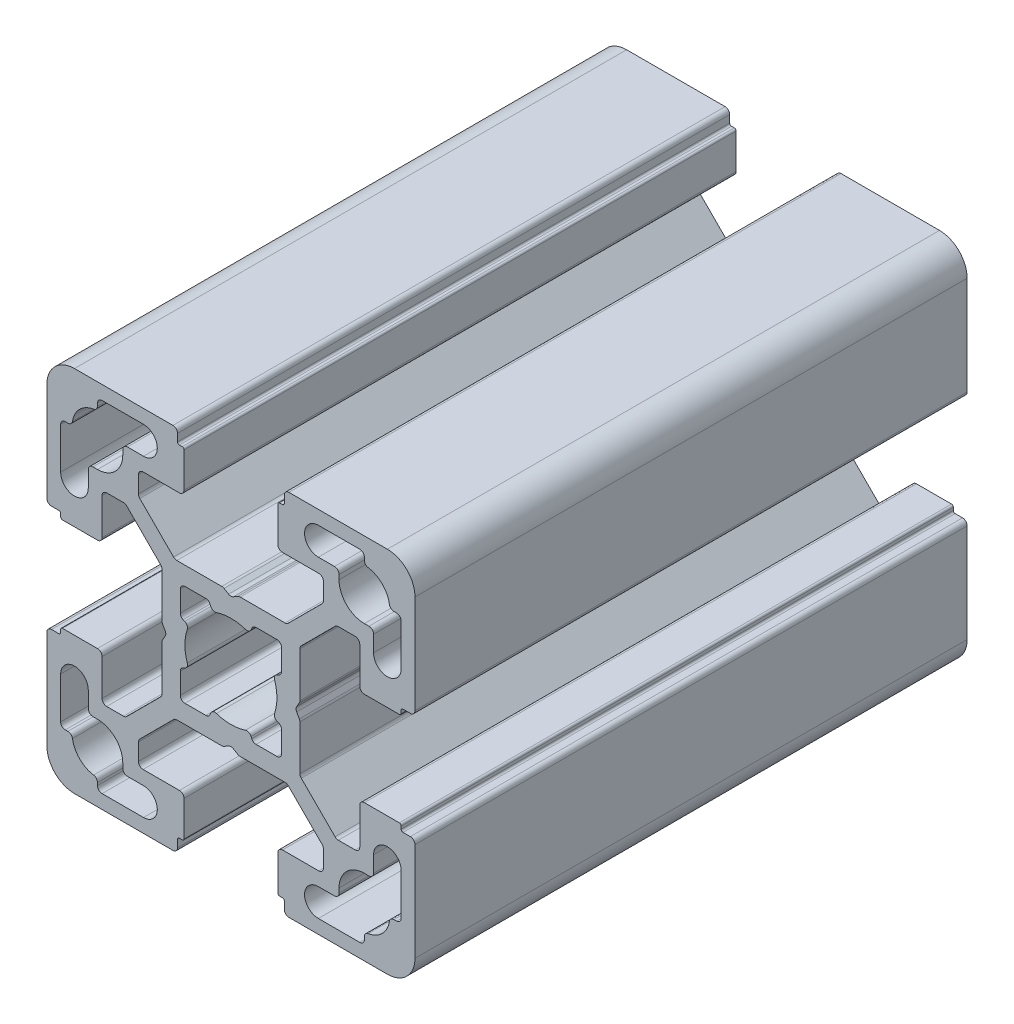
from build123d import *

# Parameters (mm, degrees)
EXTRUDE_1_DEPTH = 60


with BuildPart() as part:
    # Эскиз1 → Бобышка-Вытянуть1 (new body)
    with BuildSketch(Plane.XY):
        with BuildLine():
            Line((-18.5, -5.6), (-18.5, -5.3))
            ThreePointArc((-18.5, -5.3), (-18.441421356, -5.158578644), (-18.3, -5.1))
            Line((-18.3, -5.1), (-14.5, -5.1))
            ThreePointArc((-14.5, -5.1), (-14.146446609, -5.246446609), (-14, -5.6))
            Line((-14, -5.6), (-14, -9.55))
            ThreePointArc((-14, -9.55), (-13.853553391, -9.903553391), (-13.5, -10.05))
            Line((-13.5, -10.05), (-11.671320344, -10.05))
            ThreePointArc((-11.671320344, -10.05), (-11.479978627, -10.011939766), (-11.317766953, -9.903553391))
            Line((-11.317766953, -9.903553391), (-7.646446609, -6.232233047))
            ThreePointArc((-7.646446609, -6.232233047), (-7.538060234, -6.070021373), (-7.5, -5.878679656))
            Line((-7.5, -5.878679656), (-7.5, -1))
            ThreePointArc((-7.5, -1), (-7.482962913, -0.870590477), (-7.433012702, -0.75))
            Line((-7.433012702, -0.75), (-7.144337567, -0.25))
            ThreePointArc((-7.144337567, -0.25), (-7.077350269, 0), (-7.144337567, 0.25))
            Line((-7.144337567, 0.25), (-7.433012702, 0.75))
            ThreePointArc((-7.433012702, 0.75), (-7.482962913, 0.870590477), (-7.5, 1))
            Line((-7.5, 1), (-7.5, 5.878679656))
            ThreePointArc((-7.5, 5.878679656), (-7.538060234, 6.070021373), (-7.646446609, 6.232233047))
            Line((-7.646446609, 6.232233047), (-11.317766953, 9.903553391))
            ThreePointArc((-11.317766953, 9.903553391), (-11.479978627, 10.011939766), (-11.671320344, 10.05))
            Line((-11.671320344, 10.05), (-13.5, 10.05))
            ThreePointArc((-13.5, 10.05), (-13.853553391, 9.903553391), (-14, 9.55))
            Line((-14, 9.55), (-14, 5.6))
            ThreePointArc((-14, 5.6), (-14.146446609, 5.246446609), (-14.5, 5.1))
            Line((-14.5, 5.1), (-18.3, 5.1))
            ThreePointArc((-18.3, 5.1), (-18.441421356, 5.158578644), (-18.5, 5.3))
            Line((-18.5, 5.3), (-18.5, 5.6))
            ThreePointArc((-18.5, 5.6), (-18.558578644, 5.741421356), (-18.7, 5.8))
            Line((-18.7, 5.8), (-19.5, 5.8))
            ThreePointArc((-19.5, 5.8), (-19.853553391, 5.946446609), (-20, 6.3))
            Line((-20, 6.3), (-20, 17))
            ThreePointArc((-20, 17), (-19.121320344, 19.121320344), (-17, 20))
            Line((-17, 20), (-6.3, 20))
            ThreePointArc((-6.3, 20), (-5.946446609, 19.853553391), (-5.8, 19.5))
            Line((-5.8, 19.5), (-5.8, 18.7))
            ThreePointArc((-5.8, 18.7), (-5.741421356, 18.558578644), (-5.6, 18.5))
            Line((-5.6, 18.5), (-5.3, 18.5))
            ThreePointArc((-5.3, 18.5), (-5.158578644, 18.441421356), (-5.1, 18.3))
            Line((-5.1, 18.3), (-5.1, 14.5))
            ThreePointArc((-5.1, 14.5), (-5.246446609, 14.146446609), (-5.6, 14))
            Line((-5.6, 14), (-9.55, 14))
            ThreePointArc((-9.55, 14), (-9.903553391, 13.853553391), (-10.05, 13.5))
            Line((-10.05, 13.5), (-10.05, 11.671320344))
            ThreePointArc((-10.05, 11.671320344), (-10.011939766, 11.479978627), (-9.903553391, 11.317766953))
            Line((-9.903553391, 11.317766953), (-6.232233047, 7.646446609))
            ThreePointArc((-6.232233047, 7.646446609), (-6.070021373, 7.538060234), (-5.878679656, 7.5))
            Line((-5.878679656, 7.5), (-1, 7.5))
            ThreePointArc((-1, 7.5), (-0.870590477, 7.482962913), (-0.75, 7.433012702))
            Line((-0.75, 7.433012702), (-0.25, 7.144337567))
            ThreePointArc((-0.25, 7.144337567), (0, 7.077350269), (0.25, 7.144337567))
            Line((0.25, 7.144337567), (0.75, 7.433012702))
            ThreePointArc((0.75, 7.433012702), (0.870590477, 7.482962913), (1, 7.5))
            Line((1, 7.5), (5.878679656, 7.5))
            ThreePointArc((5.878679656, 7.5), (6.070021373, 7.538060234), (6.232233047, 7.646446609))
            Line((6.232233047, 7.646446609), (9.903553391, 11.317766953))
            ThreePointArc((9.903553391, 11.317766953), (10.011939766, 11.479978627), (10.05, 11.671320344))
            Line((10.05, 11.671320344), (10.05, 13.5))
            ThreePointArc((10.05, 13.5), (9.903553391, 13.853553391), (9.55, 14))
            Line((9.55, 14), (5.6, 14))
            ThreePointArc((5.6, 14), (5.246446609, 14.146446609), (5.1, 14.5))
            Line((5.1, 14.5), (5.1, 18.3))
            ThreePointArc((5.1, 18.3), (5.158578644, 18.441421356), (5.3, 18.5))
            Line((5.3, 18.5), (5.6, 18.5))
            ThreePointArc((5.6, 18.5), (5.741421356, 18.558578644), (5.8, 18.7))
            Line((5.8, 18.7), (5.8, 19.5))
            ThreePointArc((5.8, 19.5), (5.946446609, 19.853553391), (6.3, 20))
            Line((6.3, 20), (17, 20))
            ThreePointArc((17, 20), (19.121320344, 19.121320344), (20, 17))
            Line((20, 17), (20, 6.3))
            ThreePointArc((20, 6.3), (19.853553391, 5.946446609), (19.5, 5.8))
            Line((19.5, 5.8), (18.7, 5.8))
            ThreePointArc((18.7, 5.8), (18.558578644, 5.741421356), (18.5, 5.6))
            Line((18.5, 5.6), (18.5, 5.3))
            ThreePointArc((18.5, 5.3), (18.441421356, 5.158578644), (18.3, 5.1))
            Line((18.3, 5.1), (14.5, 5.1))
            ThreePointArc((14.5, 5.1), (14.146446609, 5.246446609), (14, 5.6))
            Line((14, 5.6), (14, 9.55))
            ThreePointArc((14, 9.55), (13.853553391, 9.903553391), (13.5, 10.05))
            Line((13.5, 10.05), (11.671320344, 10.05))
            ThreePointArc((11.671320344, 10.05), (11.479978627, 10.011939766), (11.317766953, 9.903553391))
            Line((11.317766953, 9.903553391), (7.646446609, 6.232233047))
            ThreePointArc((7.646446609, 6.232233047), (7.538060234, 6.070021373), (7.5, 5.878679656))
            Line((7.5, 5.878679656), (7.5, 1))
            ThreePointArc((7.5, 1), (7.482962913, 0.870590477), (7.433012702, 0.75))
            Line((7.433012702, 0.75), (7.144337567, 0.25))
            ThreePointArc((7.144337567, 0.25), (7.077350269, 0), (7.144337567, -0.25))
            Line((7.144337567, -0.25), (7.433012702, -0.75))
            ThreePointArc((7.433012702, -0.75), (7.482962913, -0.870590477), (7.5, -1))
            Line((7.5, -1), (7.5, -5.878679656))
            ThreePointArc((7.5, -5.878679656), (7.538060234, -6.070021373), (7.646446609, -6.232233047))
            Line((7.646446609, -6.232233047), (11.317766953, -9.903553391))
            ThreePointArc((11.317766953, -9.903553391), (11.479978627, -10.011939766), (11.671320344, -10.05))
            Line((11.671320344, -10.05), (13.5, -10.05))
            ThreePointArc((13.5, -10.05), (13.853553391, -9.903553391), (14, -9.55))
            Line((14, -9.55), (14, -5.6))
            ThreePointArc((14, -5.6), (14.146446609, -5.246446609), (14.5, -5.1))
            Line((14.5, -5.1), (18.3, -5.1))
            ThreePointArc((18.3, -5.1), (18.441421356, -5.158578644), (18.5, -5.3))
            Line((18.5, -5.3), (18.5, -5.6))
            ThreePointArc((18.5, -5.6), (18.558578644, -5.741421356), (18.7, -5.8))
            Line((18.7, -5.8), (19.5, -5.8))
            ThreePointArc((19.5, -5.8), (19.853553391, -5.946446609), (20, -6.3))
            Line((20, -6.3), (20, -17))
            ThreePointArc((20, -17), (19.121320344, -19.121320344), (17, -20))
            Line((17, -20), (6.3, -20))
            ThreePointArc((6.3, -20), (5.946446609, -19.853553391), (5.8, -19.5))
            Line((5.8, -19.5), (5.8, -18.7))
            ThreePointArc((5.8, -18.7), (5.741421356, -18.558578644), (5.6, -18.5))
            Line((5.6, -18.5), (5.3, -18.5))
            ThreePointArc((5.3, -18.5), (5.158578644, -18.441421356), (5.1, -18.3))
            Line((5.1, -18.3), (5.1, -14.5))
            ThreePointArc((5.1, -14.5), (5.246446609, -14.146446609), (5.6, -14))
            Line((5.6, -14), (9.55, -14))
            ThreePointArc((9.55, -14), (9.903553391, -13.853553391), (10.05, -13.5))
            Line((10.05, -13.5), (10.05, -11.671320344))
            ThreePointArc((10.05, -11.671320344), (10.011939766, -11.479978627), (9.903553391, -11.317766953))
            Line((9.903553391, -11.317766953), (6.232233047, -7.646446609))
            ThreePointArc((6.232233047, -7.646446609), (6.070021373, -7.538060234), (5.878679656, -7.5))
            Line((5.878679656, -7.5), (1, -7.5))
            ThreePointArc((1, -7.5), (0.870590477, -7.482962913), (0.75, -7.433012702))
            Line((0.75, -7.433012702), (0.25, -7.144337567))
            ThreePointArc((0.25, -7.144337567), (0, -7.077350269), (-0.25, -7.144337567))
            Line((-0.25, -7.144337567), (-0.75, -7.433012702))
            ThreePointArc((-0.75, -7.433012702), (-0.870590477, -7.482962913), (-1, -7.5))
            Line((-1, -7.5), (-5.878679656, -7.5))
            ThreePointArc((-5.878679656, -7.5), (-6.070021373, -7.538060234), (-6.232233047, -7.646446609))
            Line((-6.232233047, -7.646446609), (-9.903553391, -11.317766953))
            ThreePointArc((-9.903553391, -11.317766953), (-10.011939766, -11.479978627), (-10.05, -11.671320344))
            Line((-10.05, -11.671320344), (-10.05, -13.5))
            ThreePointArc((-10.05, -13.5), (-9.903553391, -13.853553391), (-9.55, -14))
            Line((-9.55, -14), (-5.6, -14))
            ThreePointArc((-5.6, -14), (-5.246446609, -14.146446609), (-5.1, -14.5))
            Line((-5.1, -14.5), (-5.1, -18.3))
            ThreePointArc((-5.1, -18.3), (-5.158578644, -18.441421356), (-5.3, -18.5))
            Line((-5.3, -18.5), (-5.6, -18.5))
            ThreePointArc((-5.6, -18.5), (-5.741421356, -18.558578644), (-5.8, -18.7))
            Line((-5.8, -18.7), (-5.8, -19.5))
            ThreePointArc((-5.8, -19.5), (-5.946446609, -19.853553391), (-6.3, -20))
            Line((-6.3, -20), (-17, -20))
            ThreePointArc((-17, -20), (-19.121320344, -19.121320344), (-20, -17))
            Line((-20, -17), (-20, -6.3))
            ThreePointArc((-20, -6.3), (-19.853553391, -5.946446609), (-19.5, -5.8))
            Line((-19.5, -5.8), (-18.7, -5.8))
            ThreePointArc((-18.7, -5.8), (-18.558578644, -5.741421356), (-18.5, -5.6))
        make_face()
        with BuildLine():
            Line((-14.5, 18), (-14.5, 17.711308145))
            ThreePointArc((-14.5, 17.711308145), (-14.620222737, 17.386086327), (-14.923076923, 17.217260738))
            ThreePointArc((-14.923076923, 17.217260738), (-16.444543648, 16.444543648), (-17.217260738, 14.923076923))
            ThreePointArc((-17.217260738, 14.923076923), (-17.386086327, 14.620222737), (-17.711308145, 14.5))
            Line((-17.711308145, 14.5), (-18, 14.5))
            ThreePointArc((-18, 14.5), (-18.353553391, 14.353553391), (-18.5, 14))
            Line((-18.5, 14), (-18.5, 9.5))
            ThreePointArc((-18.5, 9.5), (-17, 8), (-15.5, 9.5))
            Line((-15.5, 9.5), (-15.5, 11.25))
            ThreePointArc((-15.5, 11.25), (-15.353553391, 11.603553391), (-15, 11.75))
            Line((-15, 11.75), (-14.5, 11.75))
            ThreePointArc((-14.5, 11.75), (-12.555456352, 12.555456352), (-11.75, 14.5))
            Line((-11.75, 14.5), (-11.75, 15))
            ThreePointArc((-11.75, 15), (-11.603553391, 15.353553391), (-11.25, 15.5))
            Line((-11.25, 15.5), (-9.5, 15.5))
            ThreePointArc((-9.5, 15.5), (-8, 17), (-9.5, 18.5))
            Line((-9.5, 18.5), (-14, 18.5))
            ThreePointArc((-14, 18.5), (-14.353553391, 18.353553391), (-14.5, 18))
        make_face(mode=Mode.SUBTRACT)
        with BuildLine():
            Line((-5.199374534, 2.269284327), (-5.020474811, 2.191496514))
            ThreePointArc((-5.020474811, 2.191496514), (-4.763314859, 1.936869058), (-4.745317587, 1.57542407))
            ThreePointArc((-4.745317587, 1.57542407), (-5, 0), (-4.745317587, -1.57542407))
            ThreePointArc((-4.745317587, -1.57542407), (-4.763314859, -1.936869058), (-5.020474811, -2.191496514))
            Line((-5.020474811, -2.191496514), (-5.199374534, -2.269284327))
            ThreePointArc((-5.199374534, -2.269284327), (-5.418143078, -2.45366775), (-5.5, -2.727814365))
            Line((-5.5, -2.727814365), (-5.5, -5))
            ThreePointArc((-5.5, -5), (-5.353553391, -5.353553391), (-5, -5.5))
            Line((-5, -5.5), (-2.727814365, -5.5))
            ThreePointArc((-2.727814365, -5.5), (-2.45366775, -5.418143078), (-2.269284327, -5.199374534))
            Line((-2.269284327, -5.199374534), (-2.191496514, -5.020474811))
            ThreePointArc((-2.191496514, -5.020474811), (-1.936869058, -4.763314859), (-1.57542407, -4.745317587))
            ThreePointArc((-1.57542407, -4.745317587), (0, -5), (1.57542407, -4.745317587))
            ThreePointArc((1.57542407, -4.745317587), (1.936869058, -4.763314859), (2.191496514, -5.020474811))
            Line((2.191496514, -5.020474811), (2.269284327, -5.199374534))
            ThreePointArc((2.269284327, -5.199374534), (2.45366775, -5.418143078), (2.727814365, -5.5))
            Line((2.727814365, -5.5), (5, -5.5))
            ThreePointArc((5, -5.5), (5.353553391, -5.353553391), (5.5, -5))
            Line((5.5, -5), (5.5, -2.727814365))
            ThreePointArc((5.5, -2.727814365), (5.418143078, -2.45366775), (5.199374534, -2.269284327))
            Line((5.199374534, -2.269284327), (5.020474811, -2.191496514))
            ThreePointArc((5.020474811, -2.191496514), (4.763314859, -1.936869058), (4.745317587, -1.57542407))
            ThreePointArc((4.745317587, -1.57542407), (5, 0), (4.745317587, 1.57542407))
            ThreePointArc((4.745317587, 1.57542407), (4.763314859, 1.936869058), (5.020474811, 2.191496514))
            Line((5.020474811, 2.191496514), (5.199374534, 2.269284327))
            ThreePointArc((5.199374534, 2.269284327), (5.418143078, 2.45366775), (5.5, 2.727814365))
            Line((5.5, 2.727814365), (5.5, 5))
            ThreePointArc((5.5, 5), (5.353553391, 5.353553391), (5, 5.5))
            Line((5, 5.5), (2.727814365, 5.5))
            ThreePointArc((2.727814365, 5.5), (2.45366775, 5.418143078), (2.269284327, 5.199374534))
            Line((2.269284327, 5.199374534), (2.191496514, 5.020474811))
            ThreePointArc((2.191496514, 5.020474811), (1.936869058, 4.763314859), (1.57542407, 4.745317587))
            ThreePointArc((1.57542407, 4.745317587), (0, 5), (-1.57542407, 4.745317587))
            ThreePointArc((-1.57542407, 4.745317587), (-1.936869058, 4.763314859), (-2.191496514, 5.020474811))
            Line((-2.191496514, 5.020474811), (-2.269284327, 5.199374534))
            ThreePointArc((-2.269284327, 5.199374534), (-2.45366775, 5.418143078), (-2.727814365, 5.5))
            Line((-2.727814365, 5.5), (-5, 5.5))
            ThreePointArc((-5, 5.5), (-5.353553391, 5.353553391), (-5.5, 5))
            Line((-5.5, 5), (-5.5, 2.727814365))
            ThreePointArc((-5.5, 2.727814365), (-5.418143078, 2.45366775), (-5.199374534, 2.269284327))
        make_face(mode=Mode.SUBTRACT)
        with BuildLine():
            Line((15.5, 9.5), (15.5, 11.25))
            ThreePointArc((15.5, 11.25), (15.353553391, 11.603553391), (15, 11.75))
            Line((15, 11.75), (14.5, 11.75))
            ThreePointArc((14.5, 11.75), (12.555456352, 12.555456352), (11.75, 14.5))
            Line((11.75, 14.5), (11.75, 15))
            ThreePointArc((11.75, 15), (11.603553391, 15.353553391), (11.25, 15.5))
            Line((11.25, 15.5), (9.5, 15.5))
            ThreePointArc((9.5, 15.5), (8, 17), (9.5, 18.5))
            Line((9.5, 18.5), (14, 18.5))
            ThreePointArc((14, 18.5), (14.353553391, 18.353553391), (14.5, 18))
            Line((14.5, 18), (14.5, 17.711308145))
            ThreePointArc((14.5, 17.711308145), (14.620222737, 17.386086327), (14.923076923, 17.217260738))
            ThreePointArc((14.923076923, 17.217260738), (16.444543648, 16.444543648), (17.217260738, 14.923076923))
            ThreePointArc((17.217260738, 14.923076923), (17.386086327, 14.620222737), (17.711308145, 14.5))
            Line((17.711308145, 14.5), (18, 14.5))
            ThreePointArc((18, 14.5), (18.353553391, 14.353553391), (18.5, 14))
            Line((18.5, 14), (18.5, 9.5))
            ThreePointArc((18.5, 9.5), (17, 8), (15.5, 9.5))
        make_face(mode=Mode.SUBTRACT)
        with BuildLine():
            Line((14.5, -18), (14.5, -17.711308145))
            ThreePointArc((14.5, -17.711308145), (14.620222737, -17.386086327), (14.923076923, -17.217260738))
            ThreePointArc((14.923076923, -17.217260738), (16.444543648, -16.444543648), (17.217260738, -14.923076923))
            ThreePointArc((17.217260738, -14.923076923), (17.386086327, -14.620222737), (17.711308145, -14.5))
            Line((17.711308145, -14.5), (18, -14.5))
            ThreePointArc((18, -14.5), (18.353553391, -14.353553391), (18.5, -14))
            Line((18.5, -14), (18.5, -9.5))
            ThreePointArc((18.5, -9.5), (17, -8), (15.5, -9.5))
            Line((15.5, -9.5), (15.5, -11.25))
            ThreePointArc((15.5, -11.25), (15.353553391, -11.603553391), (15, -11.75))
            Line((15, -11.75), (14.5, -11.75))
            ThreePointArc((14.5, -11.75), (12.555456352, -12.555456352), (11.75, -14.5))
            Line((11.75, -14.5), (11.75, -15))
            ThreePointArc((11.75, -15), (11.603553391, -15.353553391), (11.25, -15.5))
            Line((11.25, -15.5), (9.5, -15.5))
            ThreePointArc((9.5, -15.5), (8, -17), (9.5, -18.5))
            Line((9.5, -18.5), (14, -18.5))
            ThreePointArc((14, -18.5), (14.353553391, -18.353553391), (14.5, -18))
        make_face(mode=Mode.SUBTRACT)
        with BuildLine():
            Line((-15.5, -9.5), (-15.5, -11.25))
            ThreePointArc((-15.5, -11.25), (-15.353553391, -11.603553391), (-15, -11.75))
            Line((-15, -11.75), (-14.5, -11.75))
            ThreePointArc((-14.5, -11.75), (-12.555456352, -12.555456352), (-11.75, -14.5))
            Line((-11.75, -14.5), (-11.75, -15))
            ThreePointArc((-11.75, -15), (-11.603553391, -15.353553391), (-11.25, -15.5))
            Line((-11.25, -15.5), (-9.5, -15.5))
            ThreePointArc((-9.5, -15.5), (-8, -17), (-9.5, -18.5))
            Line((-9.5, -18.5), (-14, -18.5))
            ThreePointArc((-14, -18.5), (-14.353553391, -18.353553391), (-14.5, -18))
            Line((-14.5, -18), (-14.5, -17.711308145))
            ThreePointArc((-14.5, -17.711308145), (-14.620222737, -17.386086327), (-14.923076923, -17.217260738))
            ThreePointArc((-14.923076923, -17.217260738), (-16.444543648, -16.444543648), (-17.217260738, -14.923076923))
            ThreePointArc((-17.217260738, -14.923076923), (-17.386086327, -14.620222737), (-17.711308145, -14.5))
            Line((-17.711308145, -14.5), (-18, -14.5))
            ThreePointArc((-18, -14.5), (-18.353553391, -14.353553391), (-18.5, -14))
            Line((-18.5, -14), (-18.5, -9.5))
            ThreePointArc((-18.5, -9.5), (-17, -8), (-15.5, -9.5))
        make_face(mode=Mode.SUBTRACT)
    extrude(amount=EXTRUDE_1_DEPTH)


solid = part.part
